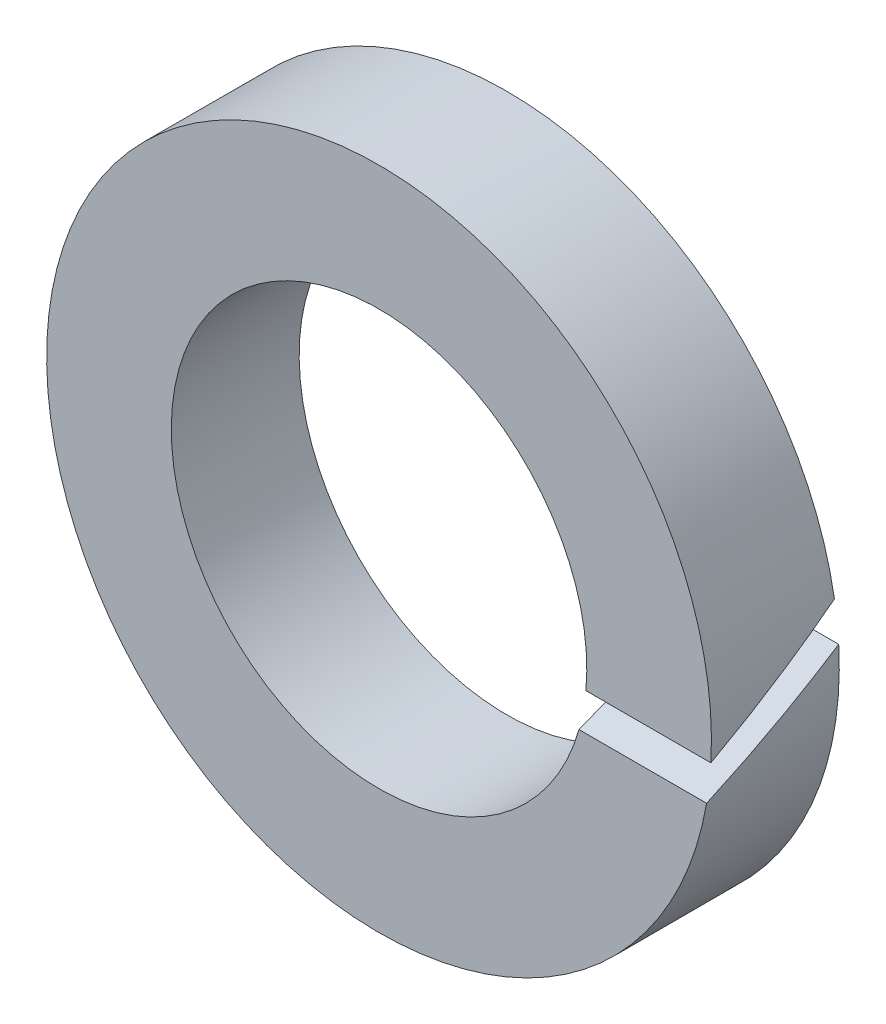
from build123d import *

# Parameters (mm, degrees)
ESQUISSE1_R             = 5.2
ESQUISSE1_R_2           = 3.25
BASE_EXTRUSION_DEPTH    = 2
ENL_V_MAT_EXTRU_1_DEPTH = 8.621023553


with BuildPart() as part:
    # Esquisse1 → Base-Extrusion (new body)
    with BuildSketch(Plane.XY):
        Circle(ESQUISSE1_R)
        Circle(ESQUISSE1_R_2, mode=Mode.SUBTRACT)
    extrude(amount=BASE_EXTRUSION_DEPTH)

    # Esquisse2 → Enlèv. mat.-Extru.1 (cut, through all)
    with BuildSketch(Plane(origin=(0, 0, 0), x_dir=(0, 0, -1), z_dir=(1, 0, 0))):
        Polygon((-2, -0.302660284), (0, 0.884053529), (0, 0.302660284), (-2, -0.884053529), align=None)
    extrude(amount=ENL_V_MAT_EXTRU_1_DEPTH, mode=Mode.SUBTRACT)


solid = part.part
